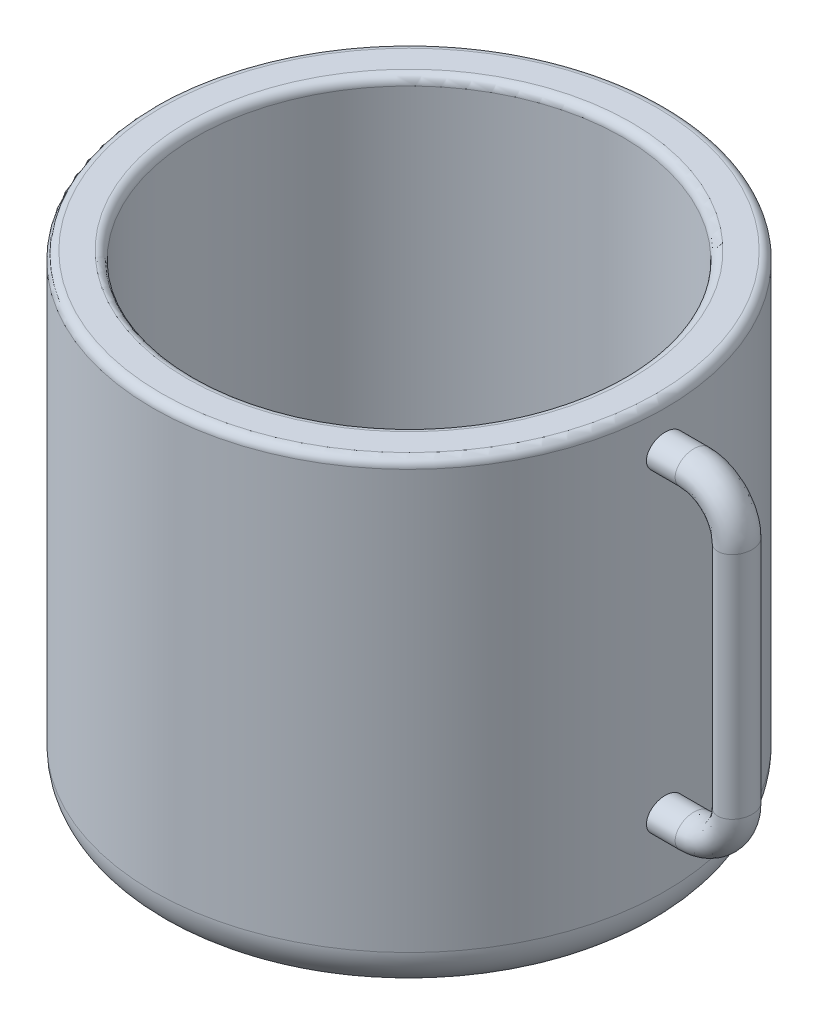
from build123d import *

# Parameters (mm, degrees)
SKETCH8_RX = 4.397360636
SKETCH8_RY = 3.639195009


with BuildPart() as part:
    # Sketch6 → Revolve7 (revolve)
    with BuildSketch(Plane.XY):
        with BuildLine():
            Line((0, 0), (0, 35.442595339))
            ThreePointArc((0, 35.442595339), (-0.585786438, 36.856808901), (-2, 37.442595339))
            Line((-2, 37.442595339), (-8, 37.442595339))
            ThreePointArc((-8, 37.442595339), (-9.414213562, 36.856808901), (-10, 35.442595339))
            Line((-10, 35.442595339), (-10, -62.557404661))
            Line((-10, -62.557404661), (-60, -62.557404661))
            Line((-60, -62.557404661), (-60, -72.557404661))
            Line((-60, -72.557404661), (-10, -72.557404661))
            ThreePointArc((-10, -72.557404661), (-2.928932188, -69.628472473), (0, -62.557404661))
            Line((0, -62.557404661), (0, 0))
        make_face()
    revolve(axis=Axis((-60, 37.442595339, 0), (0, -1, 0)))


with BuildPart() as body_2:
    # Sweep4: sweep along a path in Sketch10
    with BuildLine(Plane.XY) as sweep4_path:
        Line((0, 26.946917637), (6.72636144, 26.946917637))
        ThreePointArc((6.72636144, 26.946917637), (13.797429252, 24.017985449), (16.72636144, 16.946917637))
        Line((16.72636144, 16.946917637), (16.72636144, -36.746781296))
        ThreePointArc((16.72636144, -36.746781296), (13.797429252, -43.817849108), (6.72636144, -46.746781296))
        Line((6.72636144, -46.746781296), (0, -46.746781296))
    # Sketch8 → Sweep4 (sweep)
    with BuildSketch(Plane(origin=(0, 0, 0), x_dir=(0, 0, -1), z_dir=(1, 0, 0))):
        with Locations((0, 26.946917637)):
            Ellipse(SKETCH8_RX, SKETCH8_RY)
    sweep(path=sweep4_path.line)


solid = Compound([part.part, body_2.part])
